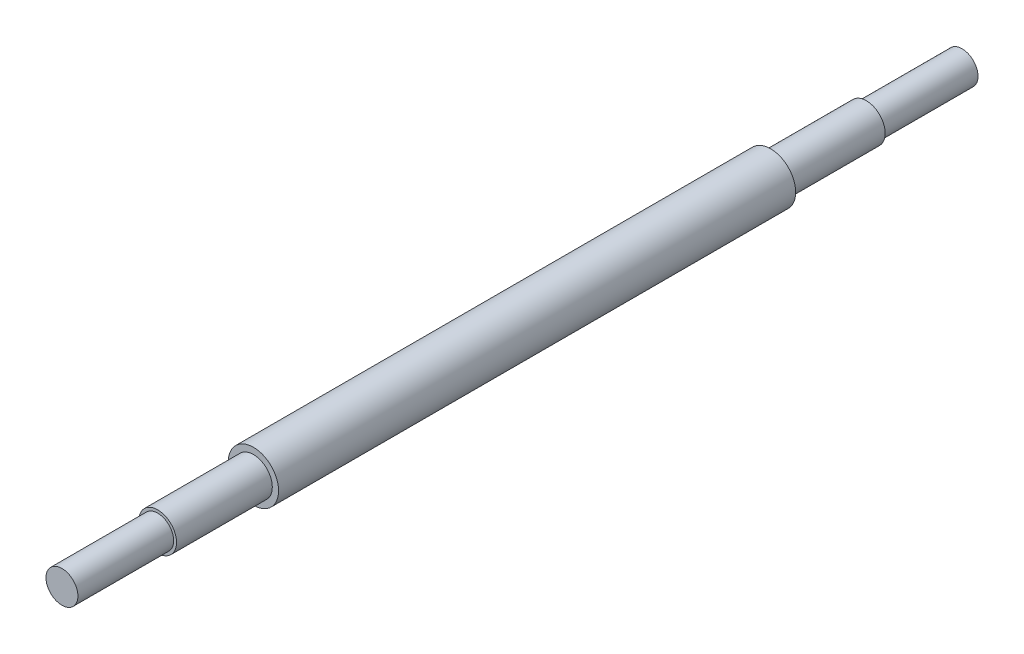
from build123d import *

# Parameters (mm, degrees)
SKETCH1_R           = 20
BOSS_EXTRUDE1_DEPTH = 411.48
SKETCH2_R           = 15
BOSS_EXTRUDE2_DEPTH = 76.2
SKETCH3_R           = 15
BOSS_EXTRUDE3_DEPTH = 76.2
SKETCH4_R           = 12.7
BOSS_EXTRUDE4_DEPTH = 76.2
SKETCH5_R           = 12.7
BOSS_EXTRUDE5_DEPTH = 76.2


with BuildPart() as part:
    # Sketch1 → Boss-Extrude1 (new body)
    with BuildSketch(Plane.XY):
        Circle(SKETCH1_R)
    extrude(amount=-BOSS_EXTRUDE1_DEPTH)

    # Sketch2 → Boss-Extrude2 (add)
    with BuildSketch(Plane.XY):
        Circle(SKETCH2_R)
    extrude(amount=BOSS_EXTRUDE2_DEPTH)

    # Sketch3 → Boss-Extrude3 (add)
    with BuildSketch(Plane(origin=(0, 0, -411.48), x_dir=(-1, 0, 0), z_dir=(0, 0, -1))):
        Circle(SKETCH3_R)
    extrude(amount=BOSS_EXTRUDE3_DEPTH)

    # Sketch4 → Boss-Extrude4 (add)
    with BuildSketch(Plane.XY.offset(76.2)):
        Circle(SKETCH4_R)
    extrude(amount=BOSS_EXTRUDE4_DEPTH)

    # Sketch5 → Boss-Extrude5 (add)
    with BuildSketch(Plane(origin=(0, 0, -487.68), x_dir=(-1, 0, 0), z_dir=(0, 0, -1))):
        Circle(SKETCH5_R)
    extrude(amount=BOSS_EXTRUDE5_DEPTH)


solid = part.part
